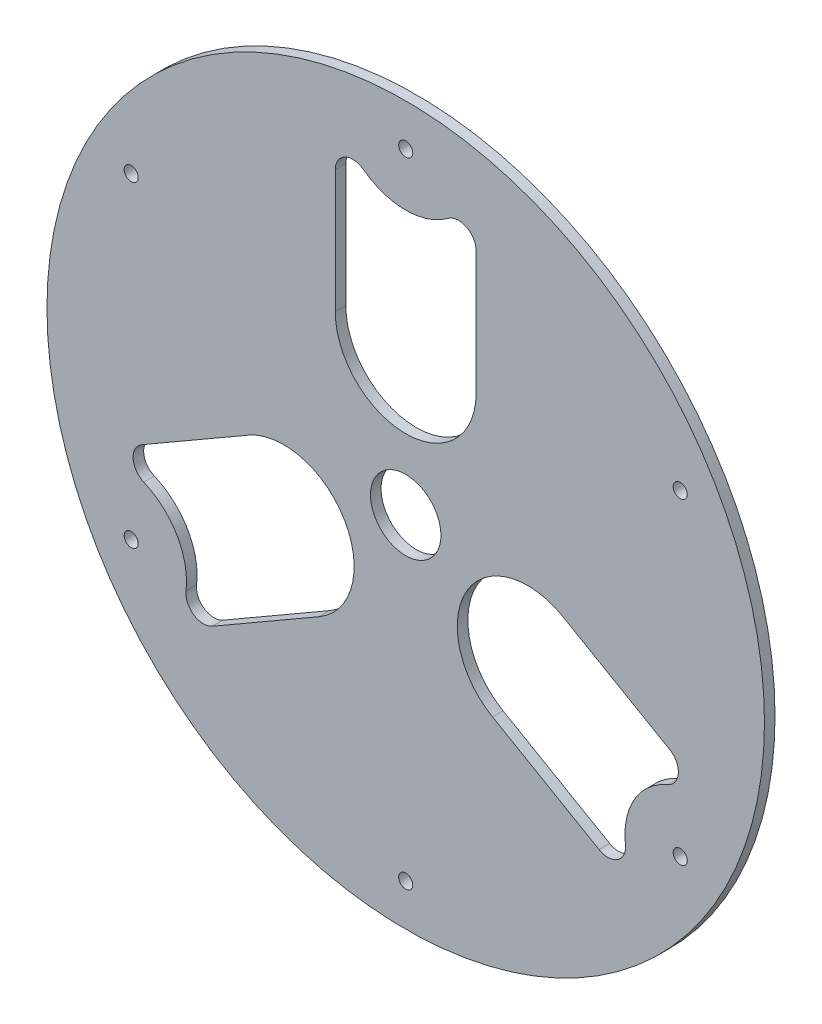
from build123d import *

# Parameters (mm, degrees)
SKETCH1_R           = 101.859163579
SKETCH1_R_2         = 2
SKETCH1_R_3         = 10
BOSS_EXTRUDE1_DEPTH = 3


with BuildPart() as part:
    # Sketch1 → Boss-Extrude1 (new body)
    with BuildSketch(Plane.XY):
        Circle(SKETCH1_R)
        with Locations((0, 90)):
            Circle(SKETCH1_R_2, mode=Mode.SUBTRACT)
        with Locations((77.942286341, 45)):
            Circle(SKETCH1_R_2, mode=Mode.SUBTRACT)
        with Locations((77.942286341, -45)):
            Circle(SKETCH1_R_2, mode=Mode.SUBTRACT)
        with Locations((0, -90)):
            Circle(SKETCH1_R_2, mode=Mode.SUBTRACT)
        with Locations((-77.942286341, -45)):
            Circle(SKETCH1_R_2, mode=Mode.SUBTRACT)
        with Locations((-77.942286341, 45)):
            Circle(SKETCH1_R_2, mode=Mode.SUBTRACT)
        Circle(SKETCH1_R_3, mode=Mode.SUBTRACT)
        with BuildLine():
            Line((-20, 74.95508592), (-20, 40))
            ThreePointArc((-20, 40), (0, 20), (20, 40))
            Line((20, 40), (20, 74.95508592))
            ThreePointArc((20, 74.95508592), (17.236067977, 79.427221875), (12, 78.95508592))
            ThreePointArc((12, 78.95508592), (0, 74.95508592), (-12, 78.95508592))
            ThreePointArc((-12, 78.95508592), (-17.236067977, 79.427221875), (-20, 74.95508592))
        make_face(mode=Mode.SUBTRACT)
        with BuildLine():
            Line((74.91300855, -20.157034884), (44.641016151, -2.679491924))
            ThreePointArc((44.641016151, -2.679491924), (17.320508076, -10), (24.641016151, -37.320508076))
            Line((24.641016151, -37.320508076), (54.91300855, -54.798051036))
            ThreePointArc((54.91300855, -54.798051036), (60.167957907, -54.640483667), (62.377110165, -49.869847805))
            ThreePointArc((62.377110165, -49.869847805), (64.91300855, -37.47754296), (74.377110165, -29.085238115))
            ThreePointArc((74.377110165, -29.085238115), (77.404025885, -24.786738208), (74.91300855, -20.157034884))
        make_face(mode=Mode.SUBTRACT)
        with BuildLine():
            Line((-54.91300855, -54.798051036), (-24.641016151, -37.320508076))
            ThreePointArc((-24.641016151, -37.320508076), (-17.320508076, -10), (-44.641016151, -2.679491924))
            Line((-44.641016151, -2.679491924), (-74.91300855, -20.157034884))
            ThreePointArc((-74.91300855, -20.157034884), (-77.404025885, -24.786738208), (-74.377110165, -29.085238115))
            ThreePointArc((-74.377110165, -29.085238115), (-64.91300855, -37.47754296), (-62.377110165, -49.869847805))
            ThreePointArc((-62.377110165, -49.869847805), (-60.167957907, -54.640483667), (-54.91300855, -54.798051036))
        make_face(mode=Mode.SUBTRACT)
    extrude(amount=BOSS_EXTRUDE1_DEPTH)


solid = part.part
